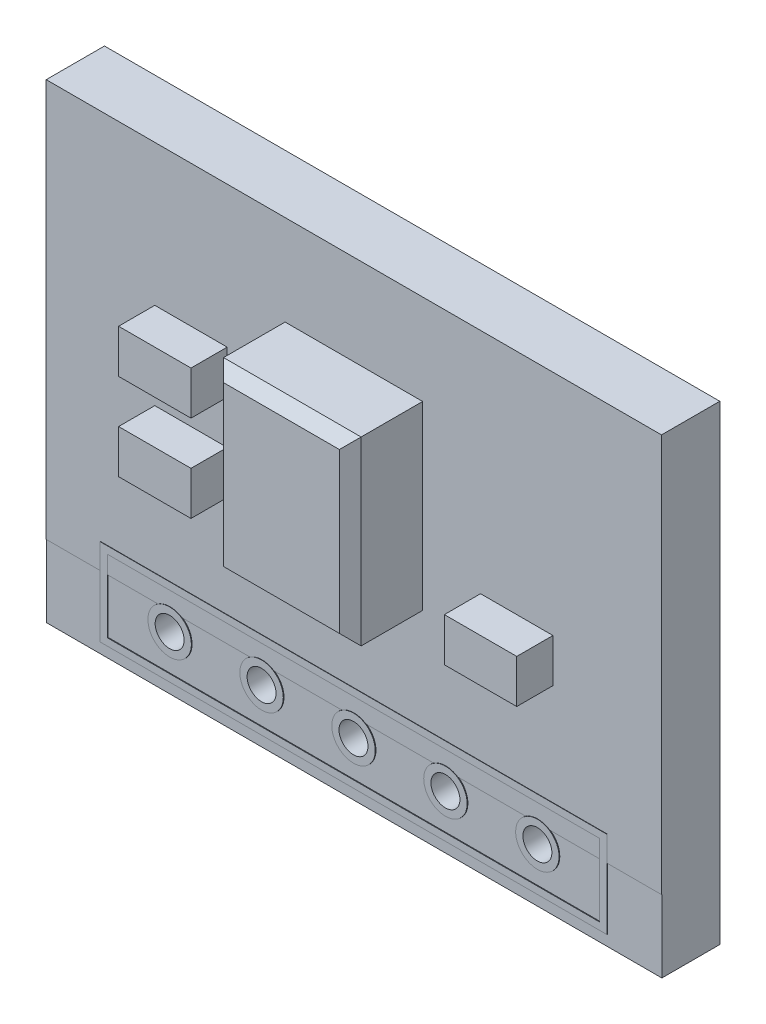
from build123d import *

# Parameters (mm, degrees)
BOSS_EXTRUDE1_DEPTH = 1.6
SKETCH2_W           = 17
SKETCH2_H           = 12
BOSS_EXTRUDE2_DEPTH = 1.61
SKETCH3_W           = 14
SKETCH3_H           = 2.4
SKETCH3_W_2         = 13.6
SKETCH3_H_2         = 2
SKETCH3_R           = 0.6
SKETCH3_R_2         = 0.4
BOSS_EXTRUDE3_DEPTH = 1.62
SKETCH3_3_R         = 0.4
CUT_EXTRUDE1_DEPTH  = 2.62
BOSS_EXTRUDE4_START = 1.61
SKETCH4_W           = 3.8
SKETCH4_H           = 5
BOSS_EXTRUDE4_DEPTH = 2
BOSS_EXTRUDE5_START = 1.61
SKETCH5_W           = 2
SKETCH5_H           = 1.2
BOSS_EXTRUDE5_DEPTH = 1
CHAMFER1_SIZE       = 0.3
SKETCH8_W           = 27
SKETCH8_H           = 26
SKETCH8_W_2         = 17
SKETCH8_H_2         = 16
CUT_EXTRUDE9_DEPTH  = 3
SKETCH9_W           = 17
SKETCH9_H           = 3
CUT_EXTRUDE11_DEPTH = 2


with BuildPart() as part:
    # Sketch1 → Boss-Extrude1 (new body)
    with BuildSketch(Plane.XY):
        Polygon((-11.5, 9.5), (-9.5, 11.5), (9.5, 11.5), (11.5, 9.5), (11.5, -9.5), (9.5, -11.5), (-9.5, -11.5), (-11.5, -9.5), align=None)
    extrude(amount=BOSS_EXTRUDE1_DEPTH)

    # Sketch2 → Boss-Extrude2 (add)
    with BuildSketch(Plane.XY):
        Rectangle(SKETCH2_W, SKETCH2_H)
    extrude(amount=BOSS_EXTRUDE2_DEPTH)

    # Sketch3 → Boss-Extrude3 (add)
    with BuildSketch(Plane.XY):
        with Locations((0, -6.5)):
            Rectangle(SKETCH3_W, SKETCH3_H)
        with Locations((0, -6.5)):
            Rectangle(SKETCH3_W_2, SKETCH3_H_2, mode=Mode.SUBTRACT)
        with Locations(Location((-5.08, -6.5, 0), (0, 0, 123.557309762))):
            Circle(SKETCH3_R)
        with Locations((-5.08, -6.5)):
            Circle(SKETCH3_R_2, mode=Mode.SUBTRACT)
        with Locations(Location((-2.54, -6.5, 0), (0, 0, 123.557309762))):
            Circle(SKETCH3_R)
        with Locations((-2.54, -6.5)):
            Circle(SKETCH3_R_2, mode=Mode.SUBTRACT)
        with Locations(Location((0, -6.5, 0), (0, 0, 123.557309762))):
            Circle(SKETCH3_R)
        with Locations((0, -6.5)):
            Circle(SKETCH3_R_2, mode=Mode.SUBTRACT)
        with Locations(Location((5.08, -6.5, 0), (0, 0, 123.557309762))):
            Circle(SKETCH3_R)
        with Locations((5.08, -6.5)):
            Circle(SKETCH3_R_2, mode=Mode.SUBTRACT)
        with Locations(Location((2.54, -6.5, 0), (0, 0, 123.557309762))):
            Circle(SKETCH3_R)
        with Locations((2.54, -6.5)):
            Circle(SKETCH3_R_2, mode=Mode.SUBTRACT)
    extrude(amount=BOSS_EXTRUDE3_DEPTH)

    # Sketch3_3 → Cut-Extrude1 (cut)
    with BuildSketch(Plane.XY):
        with Locations((-5.08, -6.5)):
            Circle(SKETCH3_3_R)
        with Locations((-2.54, -6.5)):
            Circle(SKETCH3_3_R)
        with Locations((0, -6.5)):
            Circle(SKETCH3_3_R)
        with Locations((2.54, -6.5)):
            Circle(SKETCH3_3_R)
        with Locations((5.08, -6.5)):
            Circle(SKETCH3_3_R)
    extrude(amount=CUT_EXTRUDE1_DEPTH, mode=Mode.SUBTRACT)

    # Sketch4 → Boss-Extrude4 (add)
    with BuildSketch(Plane.XY.offset(BOSS_EXTRUDE4_START)):
        Rectangle(SKETCH4_W, SKETCH4_H)
    extrude(amount=BOSS_EXTRUDE4_DEPTH)

    # Sketch5 → Boss-Extrude5 (add)
    with BuildSketch(Plane.XY.offset(BOSS_EXTRUDE5_START)):
        with Locations((-4.500129294, -1.9)):
            Rectangle(SKETCH5_W, SKETCH5_H)
        with Locations((-4.5, 0.5)):
            Rectangle(SKETCH5_W, SKETCH5_H)
        with Locations((4.5, -1.9)):
            Rectangle(SKETCH5_W, SKETCH5_H)
    extrude(amount=BOSS_EXTRUDE5_DEPTH)

    # Chamfer1
    chamfer1_edges = [part.edges().sort_by_distance(p)[0] for p in [
        (1.9, 0, 3.61),
        (0, 2.5, 3.61),
        (-1.9, 0, 3.61),
        (0, -2.5, 3.61),
    ]]
    chamfer(chamfer1_edges, length=CHAMFER1_SIZE)

    # Sketch8 → Cut-Extrude9 (cut)
    with BuildSketch(Plane.XY):
        Rectangle(SKETCH8_W, SKETCH8_H)
        Rectangle(SKETCH8_W_2, SKETCH8_H_2, mode=Mode.SUBTRACT)
    extrude(amount=CUT_EXTRUDE9_DEPTH, mode=Mode.SUBTRACT)

    # Sketch9 → Cut-Extrude11 (cut)
    with BuildSketch(Plane.XY):
        with Locations((0, 6.5)):
            Rectangle(SKETCH9_W, SKETCH9_H)
    extrude(amount=CUT_EXTRUDE11_DEPTH, mode=Mode.SUBTRACT)


solid = part.part
